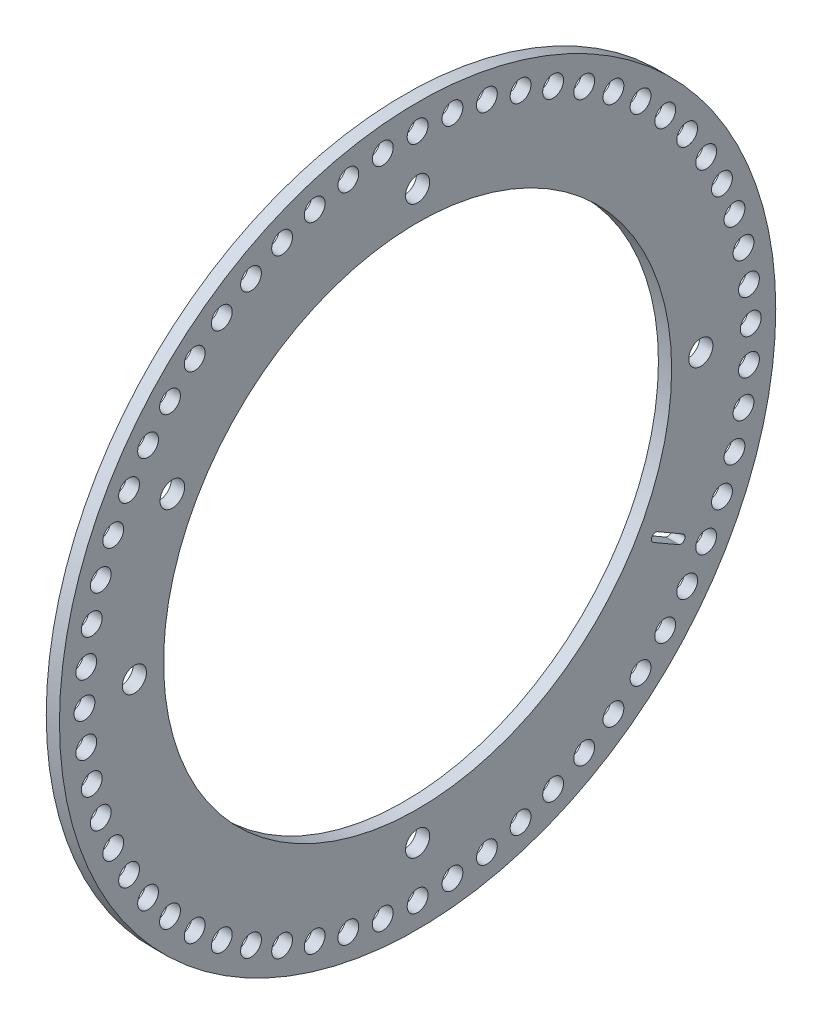
from build123d import *

# Parameters (mm, degrees)
SKETCH1_R                  = 43
SKETCH1_R_2                = 30.5
BOSS_EXTRUDE1_DEPTH        = 1.5875
SKETCH2_R                  = 1.25
SKETCH2_R_2                = 1.477643217
CUT_EXTRUDE1_DEPTH         = 2.5875
M2_5_CLEARANCE_HOLE1_D     = 2.9
M2_5_CLEARANCE_HOLE1_DEPTH = 6
M2_5_CLEARANCE_HOLE1_TIP   = 0.871247898
CUT_EXTRUDE2_DEPTH         = 2.5875


with BuildPart() as part:
    # Sketch1 → Boss-Extrude1 (new body)
    with BuildSketch(Plane(origin=(0, 0, 0), x_dir=(0, 0, -1), z_dir=(1, 0, 0))):
        Circle(SKETCH1_R)
        Circle(SKETCH1_R_2, mode=Mode.SUBTRACT)
    extrude(amount=BOSS_EXTRUDE1_DEPTH)

    # Sketch2 → Cut-Extrude1 (cut, through all)
    with BuildSketch(Plane(origin=(1.5875, 0, 0), x_dir=(0, 0, -1), z_dir=(1, 0, 0))):
        with Locations((0, 40)):
            Circle(SKETCH2_R)
        with Locations((4.181138531, 39.780875815)):
            Circle(SKETCH2_R)
        with Locations((8.316467633, 39.125904029)):
            Circle(SKETCH2_R)
        with Locations((12.360679775, 38.042260652)):
            Circle(SKETCH2_R)
        with Locations((16.269465723, 36.541818306)):
            Circle(SKETCH2_R)
        with Locations((20, 34.641016151)):
            Circle(SKETCH2_R)
        with Locations((23.511410092, 32.360679775)):
            Circle(SKETCH2_R)
        with Locations((26.765224254, 29.725793019)):
            Circle(SKETCH2_R)
        with Locations((29.725793019, 26.765224254)):
            Circle(SKETCH2_R)
        with Locations((32.360679775, 23.511410092)):
            Circle(SKETCH2_R)
        with Locations((34.641016151, 20)):
            Circle(SKETCH2_R)
        with Locations((36.541818306, 16.269465723)):
            Circle(SKETCH2_R)
        with Locations((38.042260652, 12.360679775)):
            Circle(SKETCH2_R)
        with Locations((39.125904029, 8.316467633)):
            Circle(SKETCH2_R)
        with Locations((39.780875815, 4.181138531)):
            Circle(SKETCH2_R)
        with Locations((40, 0)):
            Circle(SKETCH2_R)
        with Locations((39.780875815, -4.181138531)):
            Circle(SKETCH2_R)
        with Locations((39.125904029, -8.316467633)):
            Circle(SKETCH2_R)
        with Locations((38.042260652, -12.360679775)):
            Circle(SKETCH2_R)
        with Locations((36.541818306, -16.269465723)):
            Circle(SKETCH2_R)
        with Locations((34.641016151, -20)):
            Circle(SKETCH2_R)
        with Locations((32.360679775, -23.511410092)):
            Circle(SKETCH2_R)
        with Locations((29.725793019, -26.765224254)):
            Circle(SKETCH2_R)
        with Locations((26.765224254, -29.725793019)):
            Circle(SKETCH2_R)
        with Locations((23.511410092, -32.360679775)):
            Circle(SKETCH2_R)
        with Locations((20, -34.641016151)):
            Circle(SKETCH2_R)
        with Locations((16.269465723, -36.541818306)):
            Circle(SKETCH2_R)
        with Locations((12.360679775, -38.042260652)):
            Circle(SKETCH2_R)
        with Locations((8.316467633, -39.125904029)):
            Circle(SKETCH2_R)
        with Locations((4.181138531, -39.780875815)):
            Circle(SKETCH2_R)
        with Locations((0, -40)):
            Circle(SKETCH2_R)
        with Locations((-4.181138531, -39.780875815)):
            Circle(SKETCH2_R)
        with Locations((-8.316467633, -39.125904029)):
            Circle(SKETCH2_R)
        with Locations((-12.360679775, -38.042260652)):
            Circle(SKETCH2_R)
        with Locations((-16.269465723, -36.541818306)):
            Circle(SKETCH2_R)
        with Locations((-20, -34.641016151)):
            Circle(SKETCH2_R)
        with Locations((-23.511410092, -32.360679775)):
            Circle(SKETCH2_R)
        with Locations((-26.765224254, -29.725793019)):
            Circle(SKETCH2_R)
        with Locations((-29.725793019, -26.765224254)):
            Circle(SKETCH2_R)
        with Locations((-32.360679775, -23.511410092)):
            Circle(SKETCH2_R)
        with Locations((-34.641016151, -20)):
            Circle(SKETCH2_R)
        with Locations((-36.541818306, -16.269465723)):
            Circle(SKETCH2_R)
        with Locations((-38.042260652, -12.360679775)):
            Circle(SKETCH2_R)
        with Locations((-39.125904029, -8.316467633)):
            Circle(SKETCH2_R)
        with Locations((-39.780875815, -4.181138531)):
            Circle(SKETCH2_R)
        with Locations((-40, 0)):
            Circle(SKETCH2_R)
        with Locations((-39.780875815, 4.181138531)):
            Circle(SKETCH2_R)
        with Locations((-39.125904029, 8.316467633)):
            Circle(SKETCH2_R)
        with Locations((-38.042260652, 12.360679775)):
            Circle(SKETCH2_R)
        with Locations((-36.541818306, 16.269465723)):
            Circle(SKETCH2_R)
        with Locations((-34.641016151, 20)):
            Circle(SKETCH2_R)
        with Locations((-32.360679775, 23.511410092)):
            Circle(SKETCH2_R)
        with Locations((-29.725793019, 26.765224254)):
            Circle(SKETCH2_R)
        with Locations((-26.765224254, 29.725793019)):
            Circle(SKETCH2_R)
        with Locations((-23.511410092, 32.360679775)):
            Circle(SKETCH2_R)
        with Locations((-20, 34.641016151)):
            Circle(SKETCH2_R)
        with Locations((-16.269465723, 36.541818306)):
            Circle(SKETCH2_R)
        with Locations((-12.360679775, 38.042260652)):
            Circle(SKETCH2_R)
        with Locations((-8.316467633, 39.125904029)):
            Circle(SKETCH2_R)
        with Locations((-4.181138531, 39.780875815)):
            Circle(SKETCH2_R)
        with Locations((-29.444863729, 17)):
            Circle(SKETCH2_R_2)
    extrude(amount=-CUT_EXTRUDE1_DEPTH, mode=Mode.SUBTRACT)

    # M2.5 Clearance Hole1
    with Locations(Plane(origin=(1.5875, 0, 0), x_dir=(0, 0, -1), z_dir=(1, 0, 0))):
        with Locations((0, 34), (-34, 0), (34, 0), (0, -34)):
            Hole(M2_5_CLEARANCE_HOLE1_D / 2, depth=M2_5_CLEARANCE_HOLE1_DEPTH)
            with Locations((0, 0, -(M2_5_CLEARANCE_HOLE1_DEPTH + M2_5_CLEARANCE_HOLE1_TIP / 2))):  # 118° drill point
                Cone(0, M2_5_CLEARANCE_HOLE1_D / 2, M2_5_CLEARANCE_HOLE1_TIP, mode=Mode.SUBTRACT)

    # Sketch6 → Cut-Extrude2 (cut, through all)
    with BuildSketch(Plane(origin=(1.5875, 0, 0), x_dir=(0, 0, -1), z_dir=(1, 0, 0))):
        with BuildLine():
            Line((28.828838325, -16.066987298), (31.859927238, -17.816987298))
            ThreePointArc((31.859927238, -17.816987298), (32.04293994, -18.5), (31.359927238, -18.683012702))
            Line((31.359927238, -18.683012702), (28.328838325, -16.933012702))
            ThreePointArc((28.328838325, -16.933012702), (28.145825623, -16.25), (28.828838325, -16.066987298))
        make_face()
    extrude(amount=-CUT_EXTRUDE2_DEPTH, mode=Mode.SUBTRACT)


solid = part.part
